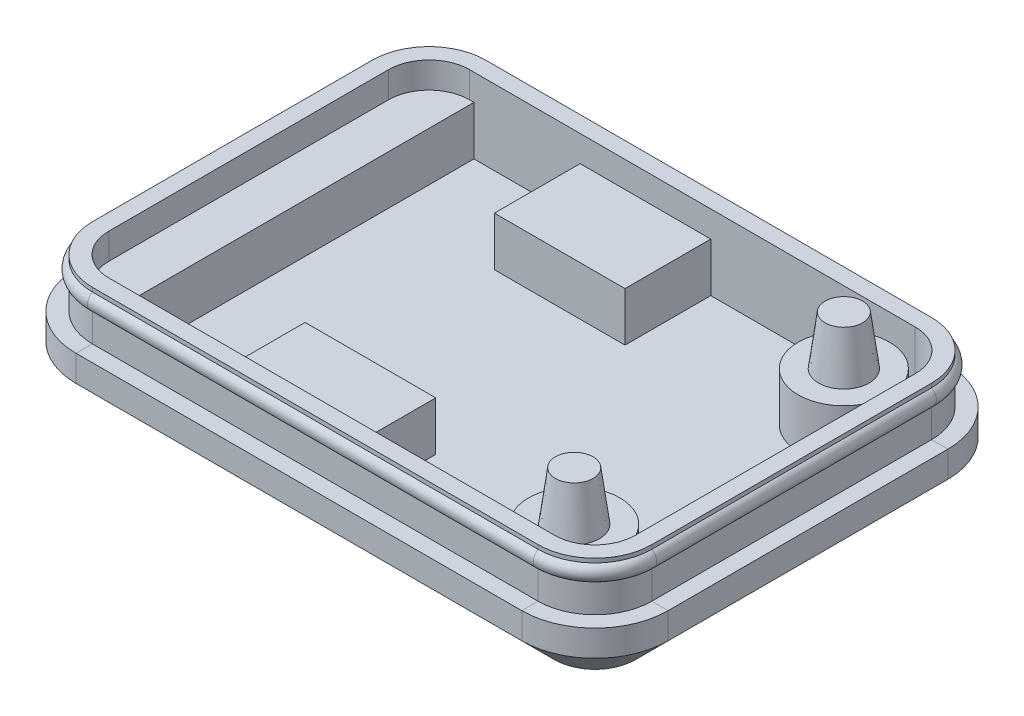
from build123d import *

# Parameters (mm, degrees)
MAIN_EXTRUSION_DEPTH      = 1.6
MAIN_EXTRUSION_DEPTH_BACK = 3
TAPERED_BOTTOM_DEPTH      = 2
TAPERED_BOTTOM_TAPER      = 45
PCB_SUPPORT_REACH         = 7
SKETCH4_R                 = 2.795
SKETCH4_W                 = 2.75
SKETCH4_H                 = 22.09
SKETCH4_W_2               = 8
SKETCH4_H_2               = 5.25
SKETCH5_R                 = 1.545
GUIDE_PINS_DEPTH          = 3
GUIDE_PINS_TAPER          = 7.5


with BuildPart() as part:
    # Sketch2 → main-extrusion (new body, two sides)
    with BuildSketch(Plane(origin=(0, 0, 0), x_dir=(1, 0, 0), z_dir=(0, 1, 0))) as main_extrusion_sk:
        with BuildLine():
            Line((-2.25, 19.36), (-2.25, 2.23))
            ThreePointArc((-2.25, 2.23), (-0.93783838, -0.93783838), (2.23, -2.25))
            Line((2.23, -2.25), (29.52, -2.25))
            ThreePointArc((29.52, -2.25), (32.68783838, -0.93783838), (34, 2.23))
            Line((34, 2.23), (34, 19.36))
            ThreePointArc((34, 19.36), (32.68783838, 22.52783838), (29.52, 23.84))
            Line((29.52, 23.84), (2.23, 23.84))
            ThreePointArc((2.23, 23.84), (-0.93783838, 22.52783838), (-2.25, 19.36))
        make_face()
        with BuildLine():
            Line((-0.25, 19.36), (-0.25, 2.23))
            ThreePointArc((-0.25, 2.23), (0.476375183, 0.476375183), (2.23, -0.25))
            Line((2.23, -0.25), (29.52, -0.25))
            ThreePointArc((29.52, -0.25), (31.273624817, 0.476375183), (32, 2.23))
            Line((32, 2.23), (32, 19.36))
            ThreePointArc((32, 19.36), (31.273624817, 21.113624817), (29.52, 21.84))
            Line((29.52, 21.84), (2.23, 21.84))
            ThreePointArc((2.23, 21.84), (0.476375183, 21.113624817), (-0.25, 19.36))
        make_face(mode=Mode.SUBTRACT)
    extrude(amount=MAIN_EXTRUSION_DEPTH)
    extrude(main_extrusion_sk.sketch, amount=-MAIN_EXTRUSION_DEPTH_BACK)

    # Sketch3 → tapered-bottom (add)
    with BuildSketch(Plane.XZ.offset(3)):
        with BuildLine():
            ThreePointArc((-2.25, -19.36), (-0.93783838, -22.52783838), (2.23, -23.84))
            Line((2.23, -23.84), (29.52, -23.84))
            ThreePointArc((29.52, -23.84), (32.68783838, -22.52783838), (34, -19.36))
            Line((34, -19.36), (34, -2.23))
            ThreePointArc((34, -2.23), (32.68783838, 0.93783838), (29.52, 2.25))
            Line((29.52, 2.25), (2.23, 2.25))
            ThreePointArc((2.23, 2.25), (-0.93783838, 0.93783838), (-2.25, -2.23))
            Line((-2.25, -2.23), (-2.25, -19.36))
        make_face()
    extrude(amount=TAPERED_BOTTOM_DEPTH, taper=TAPERED_BOTTOM_TAPER)

    # Sketch4 → PCB-support (add, up to next)
    with BuildSketch(Plane(origin=(0, 0, 0), x_dir=(1, 0, 0), z_dir=(0, 1, 0)), mode=Mode.PRIVATE) as pcb_support_sk1:
        with Locations((27.94, 19.05)):
            Circle(SKETCH4_R)
    pcb_support_tool1 = extrude(pcb_support_sk1.sketch, amount=-PCB_SUPPORT_REACH, mode=Mode.PRIVATE) - part.part
    add(pcb_support_tool1.solids().sort_by_distance((27.94, 0, -19.05))[0])
    # Sketch4 → PCB-support (add, up to next)
    with BuildSketch(Plane(origin=(0, 0, 0), x_dir=(1, 0, 0), z_dir=(0, 1, 0)), mode=Mode.PRIVATE) as pcb_support_sk2:
        with Locations((27.94, 2.54)):
            Circle(SKETCH4_R)
    pcb_support_tool2 = extrude(pcb_support_sk2.sketch, amount=-PCB_SUPPORT_REACH, mode=Mode.PRIVATE) - part.part
    add(pcb_support_tool2.solids().sort_by_distance((27.94, 0, -2.54))[0])
    # Sketch4 → PCB-support (add, up to next)
    with BuildSketch(Plane(origin=(0, 0, 0), x_dir=(1, 0, 0), z_dir=(0, 1, 0)), mode=Mode.PRIVATE) as pcb_support_sk3:
        with Locations((1.125, 10.795)):
            Rectangle(SKETCH4_W, SKETCH4_H)
    pcb_support_tool3 = extrude(pcb_support_sk3.sketch, amount=-PCB_SUPPORT_REACH, mode=Mode.PRIVATE) - part.part
    add(pcb_support_tool3.solids().sort_by_distance((1.125, 0, -10.795))[0])
    # Sketch4 → PCB-support (add, up to next)
    with BuildSketch(Plane(origin=(0, 0, 0), x_dir=(1, 0, 0), z_dir=(0, 1, 0)), mode=Mode.PRIVATE) as pcb_support_sk4:
        with Locations((13, 19.215)):
            Rectangle(SKETCH4_W_2, SKETCH4_H_2)
    pcb_support_tool4 = extrude(pcb_support_sk4.sketch, amount=-PCB_SUPPORT_REACH, mode=Mode.PRIVATE) - part.part
    add(pcb_support_tool4.solids().sort_by_distance((13, 0, -19.215))[0])
    # Sketch4 → PCB-support (add, up to next)
    with BuildSketch(Plane(origin=(0, 0, 0), x_dir=(1, 0, 0), z_dir=(0, 1, 0)), mode=Mode.PRIVATE) as pcb_support_sk5:
        with Locations((13, 2.375)):
            Rectangle(SKETCH4_W_2, SKETCH4_H_2)
    pcb_support_tool5 = extrude(pcb_support_sk5.sketch, amount=-PCB_SUPPORT_REACH, mode=Mode.PRIVATE) - part.part
    add(pcb_support_tool5.solids().sort_by_distance((13, 0, -2.375))[0])

    # Sketch5 → guide-pins (add)
    with BuildSketch(Plane(origin=(0, 0, 0), x_dir=(1, 0, 0), z_dir=(0, 1, 0))):
        with Locations((27.94, 19.05)):
            Circle(SKETCH5_R)
        with Locations((27.94, 2.54)):
            Circle(SKETCH5_R)
    extrude(amount=GUIDE_PINS_DEPTH, taper=GUIDE_PINS_TAPER)

    # top-ridge: sweep along a path in path
    with BuildLine(Plane(origin=(0, 1.6, 0), x_dir=(1, 0, 0), z_dir=(0, 1, 0))) as top_ridge_path:
        Line((2.23, -0.25), (29.52, -0.25))
        ThreePointArc((29.52, -0.25), (31.273624817, 0.476375183), (32, 2.23))
        Line((32, 2.23), (32, 19.36))
        ThreePointArc((32, 19.36), (31.273624817, 21.113624817), (29.52, 21.84))
        Line((29.52, 21.84), (2.23, 21.84))
        ThreePointArc((2.23, 21.84), (0.476375183, 21.113624817), (-0.25, 19.36))
        Line((-0.25, 19.36), (-0.25, 2.23))
        ThreePointArc((-0.25, 2.23), (0.476375183, 0.476375183), (2.23, -0.25))
    # profile → top-ridge (sweep, cut)
    with BuildSketch(Plane(origin=(2.23, 0, 0), x_dir=(0, 0, -1), z_dir=(1, 0, 0))):
        with BuildLine():
            Line((-2.25, 1.6), (-2.25, -1.4))
            Line((-2.25, -1.4), (-1.25, -1.4))
            Line((-1.25, -1.4), (-1.25, 0.35))
            ThreePointArc((-1.25, 0.35), (-1.55, 0.85), (-1.25, 1.35))
            Line((-1.25, 1.35), (-1.25, 1.6))
            Line((-1.25, 1.6), (-2.25, 1.6))
        make_face()
    sweep(path=top_ridge_path.line, mode=Mode.SUBTRACT)


solid = part.part
